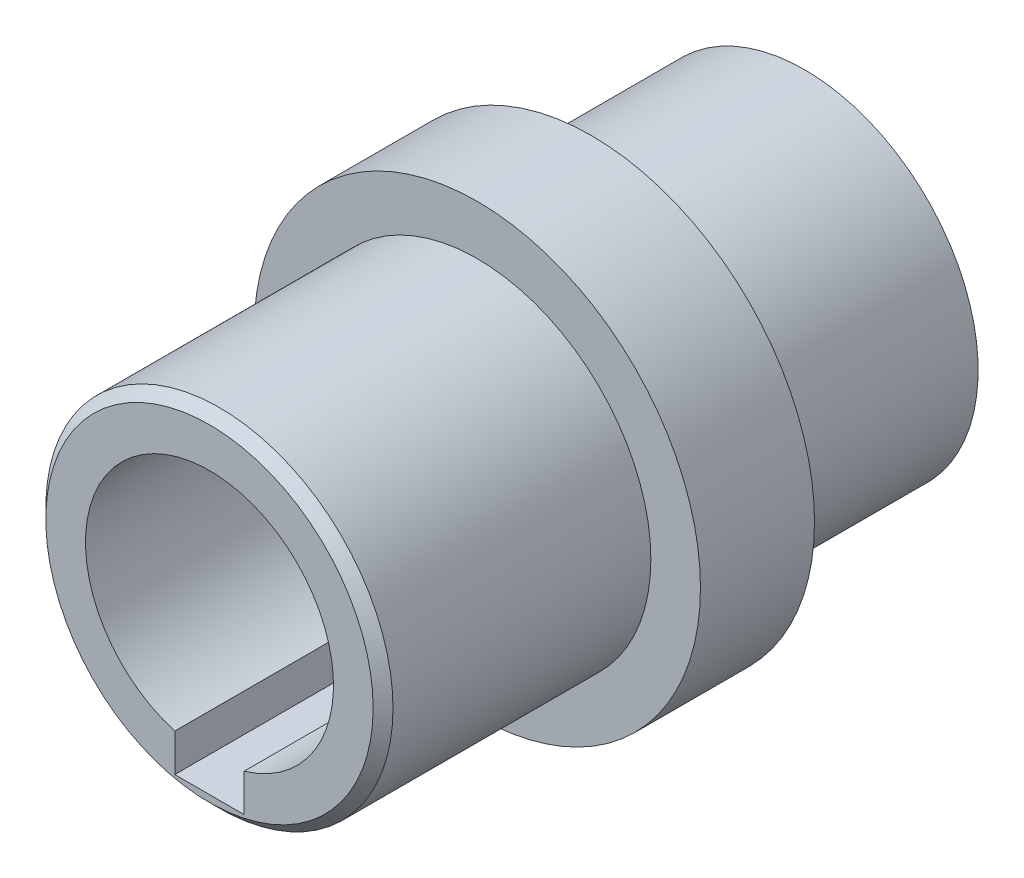
from build123d import *

# Parameters (mm, degrees)
ESQUISSE1_R             = 22.5
BOSS_EXTRU_1_DEPTH      = 60
ESQUISSE2_OUTSIDE_W     = 64.492
ESQUISSE2_OUTSIDE_H     = 64.492
ESQUISSE2_OUTSIDE_R     = 17.5
ENL_V_MAT_EXTRU_1_DEPTH = 27
ESQUISSE3_OUTSIDE_W     = 64.492
ESQUISSE3_OUTSIDE_H     = 64.492
ESQUISSE3_OUTSIDE_R     = 17.5
ENL_V_MAT_EXTRU_2_DEPTH = 21.5
ESQUISSE4_R             = 12.5
ENL_V_MAT_EXTRU_3_DEPTH = 61
ENL_V_MAT_EXTRU_4_DEPTH = 15.8
CHANFREIN1_SIZE         = 1


with BuildPart() as part:
    # Esquisse1 → Boss.-Extru.1 (new body)
    with BuildSketch(Plane.XY):
        Circle(ESQUISSE1_R)
    extrude(amount=BOSS_EXTRU_1_DEPTH)

    # Esquisse2 outside → Enlèv. mat.-Extru.1 (cut)
    with BuildSketch(Plane.XY.offset(60)):
        Rectangle(ESQUISSE2_OUTSIDE_W, ESQUISSE2_OUTSIDE_H)
        Circle(ESQUISSE2_OUTSIDE_R, mode=Mode.SUBTRACT)
    extrude(amount=-ENL_V_MAT_EXTRU_1_DEPTH, mode=Mode.SUBTRACT)

    # Esquisse3 outside → Enlèv. mat.-Extru.2 (cut)
    with BuildSketch(Plane(origin=(0, 0, 0), x_dir=(-1, 0, 0), z_dir=(0, 0, -1))):
        Rectangle(ESQUISSE3_OUTSIDE_W, ESQUISSE3_OUTSIDE_H)
        with Locations(Location((0, 0, 0), (0, 0, 180))):  # turned: the seam where the file's is
            Circle(ESQUISSE3_OUTSIDE_R, mode=Mode.SUBTRACT)
    extrude(amount=-ENL_V_MAT_EXTRU_2_DEPTH, mode=Mode.SUBTRACT)

    # Esquisse4 → Enlèv. mat.-Extru.3 (cut, through all)
    with BuildSketch(Plane.XY.offset(60)):
        Circle(ESQUISSE4_R)
    extrude(amount=-ENL_V_MAT_EXTRU_3_DEPTH, mode=Mode.SUBTRACT)

    # Esquisse6 → Enlèv. mat.-Extru.4 (cut)
    with BuildSketch(Plane(origin=(0, 0, 0), x_dir=(1, 0, 0), z_dir=(0, 1, 0))):
        with BuildLine():
            Line((-3.5, -132.654252639), (-3.5, 6.73879401))
            ThreePointArc((-3.5, 6.73879401), (0, 10.23879401), (3.5, 6.73879401))
            Line((3.5, 6.73879401), (3.5, -132.654252639))
            ThreePointArc((3.5, -132.654252639), (0, -136.154252639), (-3.5, -132.654252639))
        make_face()
    extrude(amount=-ENL_V_MAT_EXTRU_4_DEPTH, mode=Mode.SUBTRACT)

    # Chanfrein1
    chanfrein1_edges = [part.edges().sort_by_distance(p)[0] for p in [
        (-17.5, 0, 60),
    ]]
    chamfer(chanfrein1_edges, length=CHANFREIN1_SIZE)


solid = part.part
